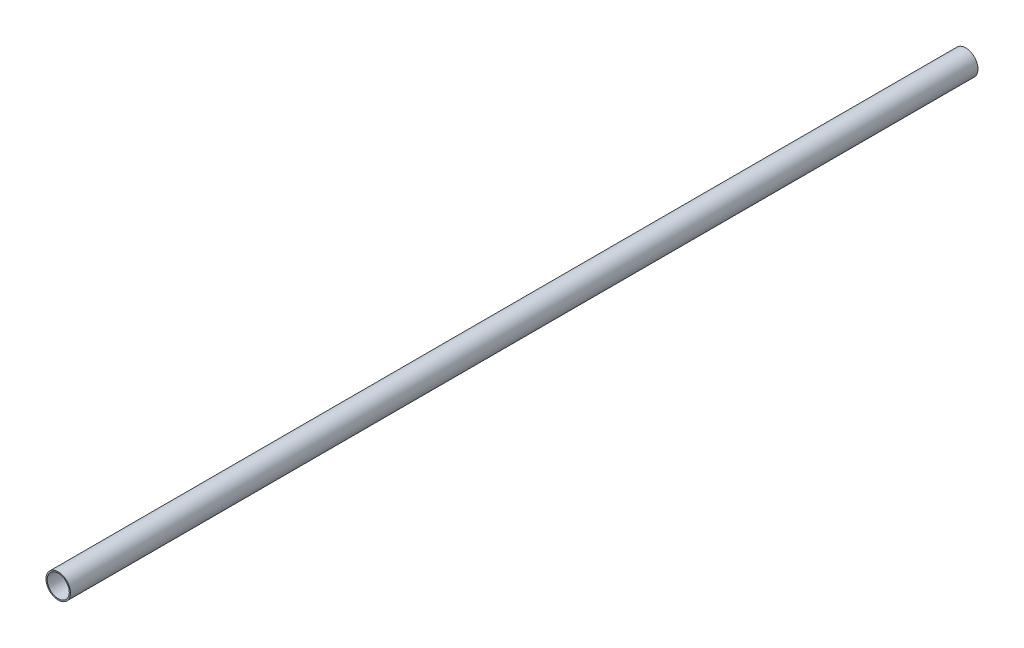
from build123d import *

# Parameters (mm, degrees)
SKETCH_1_R      = 5
SKETCH_1_R_2    = 4.5
EXTRUDE_1_DEPTH = 185


with BuildPart() as part:
    # Эскиз1 → Бобышка-Вытянуть1 (new body, symmetric)
    with BuildSketch(Plane.XY):
        Circle(SKETCH_1_R)
        Circle(SKETCH_1_R_2, mode=Mode.SUBTRACT)
    extrude(amount=EXTRUDE_1_DEPTH, both=True)


solid = part.part
